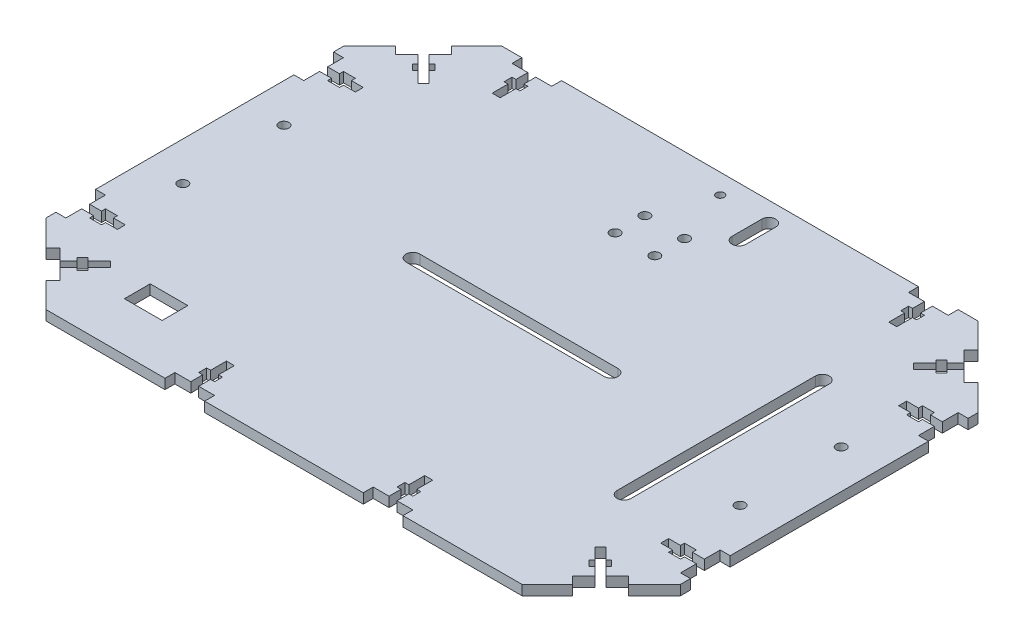
from build123d import *

# Parameters (mm, degrees)
SKETCH2_W                                    = 320
SKETCH2_H                                    = 230
BOSS_EXTRUDE1_DEPTH                          = 5
CHAMFER1_SIZE                                = 40
CHAMFER2_SIZE                                = 40
CHAMFER3_SIZE                                = 40
CHAMFER4_SIZE                                = 40
SKETCH3_R                                    = 2.5
CUT_EXTRUDE1_DEPTH                           = 10
SKETCH10_W                                   = 20
SKETCH10_H                                   = 5
SKETCH10_W_2                                 = 4
SKETCH10_H_2                                 = 18
SKETCH10_W_3                                 = 8
SKETCH10_H_3                                 = 4
CUT_EXTRUDE7_DEPTH                           = 10
SKETCH11_W                                   = 4
SKETCH11_H                                   = 6
SKETCH11_H_2                                 = 4
SKETCH11_H_3                                 = 8
SKETCH11_W_2                                 = 2
CUT_EXTRUDE8_DEPTH                           = 10
SKETCH13_W                                   = 5
SKETCH13_H                                   = 20
SKETCH13_W_2                                 = 18
SKETCH13_H_2                                 = 4
SKETCH13_W_3                                 = 6
SKETCH13_H_3                                 = 8
CUT_EXTRUDE9_DEPTH                           = 10
MIRROR4_AT_THE_SECOND_PLANE_COPY_1_SKETC_W   = 5
MIRROR4_AT_THE_SECOND_PLANE_COPY_1_SKETC_H   = 20
MIRROR4_AT_THE_SECOND_PLANE_COPY_1_SKETC_W_2 = 18
MIRROR4_AT_THE_SECOND_PLANE_COPY_1_SKETC_H_2 = 4
MIRROR4_AT_THE_SECOND_PLANE_COPY_1_SKETC_W_3 = 6
MIRROR4_AT_THE_SECOND_PLANE_COPY_1_SKETC_H_3 = 8
MIRROR4_AT_THE_SECOND_PLANE_COPY_1_DEPTH     = 10
CUT_EXTRUDE10_DEPTH                          = 10
MIRROR5_AT_THE_SECOND_PLANE_COPY_1_DEPTH     = 10
CUT_EXTRUDE11_DEPTH                          = 10
CUT_EXTRUDE12_DEPTH                          = 10
SKETCH17_R                                   = 2.5
CUT_EXTRUDE13_DEPTH                          = 10
MIRROR6_AT_THE_SECOND_PLANE_COPY_1_SKETC_R   = 2.5
MIRROR6_AT_THE_SECOND_PLANE_COPY_1_DEPTH     = 10
SKETCH18_R                                   = 2
CUT_EXTRUDE14_DEPTH                          = 8
CUT_EXTRUDE15_DEPTH                          = 10
SKETCH20_W                                   = 19
SKETCH20_H                                   = 13
CUT_EXTRUDE16_DEPTH                          = 10


with BuildPart() as part:
    # Sketch2 → Boss-Extrude1 (new body)
    with BuildSketch(Plane(origin=(0, 0, 0), x_dir=(1, 0, 0), z_dir=(0, 1, 0))):
        Rectangle(SKETCH2_W, SKETCH2_H)
    extrude(amount=BOSS_EXTRUDE1_DEPTH)

    # Chamfer1
    chamfer1_edges = [part.edges().sort_by_distance(p)[0] for p in [
        (-160, 2.5, -115),
    ]]
    chamfer(chamfer1_edges, length=CHAMFER1_SIZE)

    # Chamfer2
    chamfer2_edges = [part.edges().sort_by_distance(p)[0] for p in [
        (160, 2.5, -115),
    ]]
    chamfer(chamfer2_edges, length=CHAMFER2_SIZE)

    # Chamfer3
    chamfer3_edges = [part.edges().sort_by_distance(p)[0] for p in [
        (-160, 2.5, 115),
    ]]
    chamfer(chamfer3_edges, length=CHAMFER3_SIZE)

    # Chamfer4
    chamfer4_edges = [part.edges().sort_by_distance(p)[0] for p in [
        (160, 2.5, 115),
    ]]
    chamfer(chamfer4_edges, length=CHAMFER4_SIZE)

    # Sketch3 → Cut-Extrude1 (cut)
    with BuildSketch(Plane(origin=(0, 5, 0), x_dir=(1, 0, 0), z_dir=(0, 1, 0))):
        with Locations((-10, 77)):
            Circle(SKETCH3_R)
        with Locations((-10, 62)):
            Circle(SKETCH3_R)
    cut_extrude1 = extrude(amount=-CUT_EXTRUDE1_DEPTH, mode=Mode.SUBTRACT)

    # Mirror1: Cut-Extrude1 across plane
    add(cut_extrude1.mirror(Plane(origin=(0, 0, 0), x_dir=(0, 0, 1), z_dir=(1, 0, 0))), mode=Mode.SUBTRACT)

    # Sketch10 → Cut-Extrude7 (cut)
    with BuildSketch(Plane(origin=(0, 5, 0), x_dir=(1, 0, 0), z_dir=(0, 1, 0))):
        with Locations((50, -112.5)):
            Rectangle(SKETCH10_W, SKETCH10_H)
        with Locations((50, -101)):
            Rectangle(SKETCH10_W_2, SKETCH10_H_2)
        with Locations((50, -102)):
            Rectangle(SKETCH10_W_3, SKETCH10_H_3)
    cut_extrude7 = extrude(amount=-CUT_EXTRUDE7_DEPTH, mode=Mode.SUBTRACT)

    # Mirror2: Cut-Extrude7 across plane
    add(cut_extrude7.mirror(Plane(origin=(0, 0, 0), x_dir=(0, 0, 1), z_dir=(1, 0, 0))), mode=Mode.SUBTRACT)

    # Sketch11 → Cut-Extrude8 (cut)
    with BuildSketch(Plane(origin=(0, 5, 0), x_dir=(1, 0, 0), z_dir=(0, 1, 0))):
        Polygon((110, 115), (90, 115), (90, 110), (98, 110), (102, 110), (110, 110), align=None)
        with Locations((100, 107)):
            Rectangle(SKETCH11_W, SKETCH11_H)
        with Locations((100, 102)):
            Rectangle(SKETCH11_W, SKETCH11_H_2)
        with Locations((100, 96)):
            Rectangle(SKETCH11_W, SKETCH11_H_3)
        with Locations((103, 102)):
            Rectangle(SKETCH11_W_2, SKETCH11_H_2)
        with Locations((97, 102)):
            Rectangle(SKETCH11_W_2, SKETCH11_H_2)
    cut_extrude8 = extrude(amount=-CUT_EXTRUDE8_DEPTH, mode=Mode.SUBTRACT)

    # Mirror3: Cut-Extrude8 across plane
    add(cut_extrude8.mirror(Plane(origin=(0, 0, 0), x_dir=(0, 0, 1), z_dir=(1, 0, 0))), mode=Mode.SUBTRACT)

    # Sketch13 → Cut-Extrude9 (cut)
    with BuildSketch(Plane(origin=(0, 5, 0), x_dir=(1, 0, 0), z_dir=(0, 1, 0))):
        with Locations((-157.5, -60)):
            Rectangle(SKETCH13_W, SKETCH13_H)
        with Locations((-146, -60)):
            Rectangle(SKETCH13_W_2, SKETCH13_H_2)
        with Locations((-146, -60)):
            Rectangle(SKETCH13_W_3, SKETCH13_H_3)
    cut_extrude9 = extrude(amount=-CUT_EXTRUDE9_DEPTH, mode=Mode.SUBTRACT)

    # Mirror4: Cut-Extrude9 across plane
    add(cut_extrude9.mirror(Plane(origin=(0, 0, 0), x_dir=(0, 0, 1), z_dir=(1, 0, 0))), mode=Mode.SUBTRACT)

    # Mirror4 at the second plane: Cut-Extrude9 across plane
    add(cut_extrude9.mirror(Plane.XY), mode=Mode.SUBTRACT)

    # Mirror4 at the second plane copy 1 sketc → Mirror4 at the second plane copy 1 (cut)
    with BuildSketch(Plane(origin=(0, 5, 0), x_dir=(-1, 0, 0), z_dir=(0, 1, 0))):
        with Locations((-157.5, -60)):
            Rectangle(MIRROR4_AT_THE_SECOND_PLANE_COPY_1_SKETC_W, MIRROR4_AT_THE_SECOND_PLANE_COPY_1_SKETC_H)
        with Locations((-146, -60)):
            Rectangle(MIRROR4_AT_THE_SECOND_PLANE_COPY_1_SKETC_W_2, MIRROR4_AT_THE_SECOND_PLANE_COPY_1_SKETC_H_2)
        with Locations((-146, -60)):
            Rectangle(MIRROR4_AT_THE_SECOND_PLANE_COPY_1_SKETC_W_3, MIRROR4_AT_THE_SECOND_PLANE_COPY_1_SKETC_H_3)
    extrude(amount=-MIRROR4_AT_THE_SECOND_PLANE_COPY_1_DEPTH, mode=Mode.SUBTRACT)

    # Sketch14 → Cut-Extrude10 (cut)
    with BuildSketch(Plane(origin=(0, 5, 0), x_dir=(1, 0, 0), z_dir=(0, 1, 0))):
        Polygon((-129.192388155, -98.736544033), (-143.334523779, -84.594408409), (-146.870057685, -88.129942315), (-132.727922061, -102.272077939), align=None)
        Polygon((-133.435028843, -86.008621971), (-137.67766953, -90.251262658), (-134.849242405, -93.079689783), (-130.606601718, -88.837049096), align=None)
        Polygon((-130.606601718, -83.180194847), (-133.435028843, -86.008621971), (-130.606601718, -88.837049096), (-127.778174593, -86.008621971), align=None)
        Polygon((-124.949747468, -77.523340597), (-130.606601718, -83.180194847), (-127.778174593, -86.008621971), (-122.121320344, -80.351767722), align=None)
        Polygon((-127.778174593, -86.008621971), (-130.606601718, -88.837049096), (-129.192388155, -90.251262658), (-126.363961031, -87.422835534), align=None)
        Polygon((-134.849242405, -84.594408409), (-133.435028843, -86.008621971), (-130.606601718, -83.180194847), (-132.02081528, -81.765981284), align=None)
    cut_extrude10 = extrude(amount=-CUT_EXTRUDE10_DEPTH, mode=Mode.SUBTRACT)

    # Mirror5: Cut-Extrude10 across plane
    add(cut_extrude10.mirror(Plane(origin=(0, 0, 0), x_dir=(0, 0, 1), z_dir=(1, 0, 0))), mode=Mode.SUBTRACT)

    # Mirror5 at the second plane: Cut-Extrude10 across plane
    add(cut_extrude10.mirror(Plane.XY), mode=Mode.SUBTRACT)

    # Mirror5 at the second plane copy 1 sketc → Mirror5 at the second plane copy 1 (cut)
    with BuildSketch(Plane(origin=(0, 5, 0), x_dir=(-1, 0, 0), z_dir=(0, 1, 0))):
        Polygon((-129.192388155, -98.736544033), (-143.334523779, -84.594408409), (-146.870057685, -88.129942315), (-132.727922061, -102.272077939), align=None)
        Polygon((-133.435028843, -86.008621971), (-137.67766953, -90.251262658), (-134.849242405, -93.079689783), (-130.606601718, -88.837049096), align=None)
        Polygon((-130.606601718, -83.180194847), (-133.435028843, -86.008621971), (-130.606601718, -88.837049096), (-127.778174593, -86.008621971), align=None)
        Polygon((-124.949747468, -77.523340597), (-130.606601718, -83.180194847), (-127.778174593, -86.008621971), (-122.121320344, -80.351767722), align=None)
        Polygon((-127.778174593, -86.008621971), (-130.606601718, -88.837049096), (-129.192388155, -90.251262658), (-126.363961031, -87.422835534), align=None)
        Polygon((-134.849242405, -84.594408409), (-133.435028843, -86.008621971), (-130.606601718, -83.180194847), (-132.02081528, -81.765981284), align=None)
    extrude(amount=-MIRROR5_AT_THE_SECOND_PLANE_COPY_1_DEPTH, mode=Mode.SUBTRACT)

    # Sketch15 → Cut-Extrude11 (cut)
    with BuildSketch(Plane(origin=(0, 5, 0), x_dir=(1, 0, 0), z_dir=(0, 1, 0))):
        with BuildLine():
            Line((50, -3.5), (-50, -3.5))
            ThreePointArc((-50, -3.5), (-53.5, 0), (-50, 3.5))
            Line((-50, 3.5), (50, 3.5))
            ThreePointArc((50, 3.5), (53.5, 0), (50, -3.5))
        make_face()
    extrude(amount=-CUT_EXTRUDE11_DEPTH, mode=Mode.SUBTRACT)

    # Sketch16 → Cut-Extrude12 (cut)
    with BuildSketch(Plane(origin=(0, 5, 0), x_dir=(1, 0, 0), z_dir=(0, 1, 0))):
        with BuildLine():
            Line((110, 50), (110, -50))
            ThreePointArc((110, -50), (106.5, -53.5), (103, -50))
            Line((103, -50), (103, 50))
            ThreePointArc((103, 50), (106.5, 53.5), (110, 50))
        make_face()
    extrude(amount=-CUT_EXTRUDE12_DEPTH, mode=Mode.SUBTRACT)

    # Sketch17 → Cut-Extrude13 (cut)
    with BuildSketch(Plane(origin=(0, 5, 0), x_dir=(1, 0, 0), z_dir=(0, 1, 0))):
        with Locations((140.5, 25.5)):
            Circle(SKETCH17_R)
    cut_extrude13 = extrude(amount=-CUT_EXTRUDE13_DEPTH, mode=Mode.SUBTRACT)

    # Mirror6: Cut-Extrude13 across plane
    add(cut_extrude13.mirror(Plane(origin=(0, 0, 0), x_dir=(0, 0, 1), z_dir=(1, 0, 0))), mode=Mode.SUBTRACT)

    # Mirror6 at the second plane: Cut-Extrude13 across plane
    add(cut_extrude13.mirror(Plane.XY), mode=Mode.SUBTRACT)

    # Mirror6 at the second plane copy 1 sketc → Mirror6 at the second plane copy 1 (cut)
    with BuildSketch(Plane(origin=(0, 5, 0), x_dir=(-1, 0, 0), z_dir=(0, 1, 0))):
        with Locations((140.5, 25.5)):
            Circle(MIRROR6_AT_THE_SECOND_PLANE_COPY_1_SKETC_R)
    extrude(amount=-MIRROR6_AT_THE_SECOND_PLANE_COPY_1_DEPTH, mode=Mode.SUBTRACT)

    # Sketch18 → Cut-Extrude14 (cut)
    with BuildSketch(Plane(origin=(0, 5, 0), x_dir=(1, 0, 0), z_dir=(0, 1, 0))):
        with Locations((0, 105)):
            Circle(SKETCH18_R)
    extrude(amount=-CUT_EXTRUDE14_DEPTH, mode=Mode.SUBTRACT)

    # Sketch19 → Cut-Extrude15 (cut)
    with BuildSketch(Plane(origin=(0, 5, 0), x_dir=(1, 0, 0), z_dir=(0, 1, 0))):
        with BuildLine():
            Line((27.971925675, 105), (27.971925675, 90))
            ThreePointArc((27.971925675, 90), (24.471925675, 86.5), (20.971925675, 90))
            Line((20.971925675, 90), (20.971925675, 105))
            ThreePointArc((20.971925675, 105), (24.471925675, 108.5), (27.971925675, 105))
        make_face()
    extrude(amount=-CUT_EXTRUDE15_DEPTH, mode=Mode.SUBTRACT)

    # Sketch20 → Cut-Extrude16 (cut)
    with BuildSketch(Plane(origin=(0, 5, 0), x_dir=(1, 0, 0), z_dir=(0, 1, 0))):
        with Locations((-95.462822942, -83.993915469)):
            Rectangle(SKETCH20_W, SKETCH20_H)
    extrude(amount=-CUT_EXTRUDE16_DEPTH, mode=Mode.SUBTRACT)


solid = part.part
